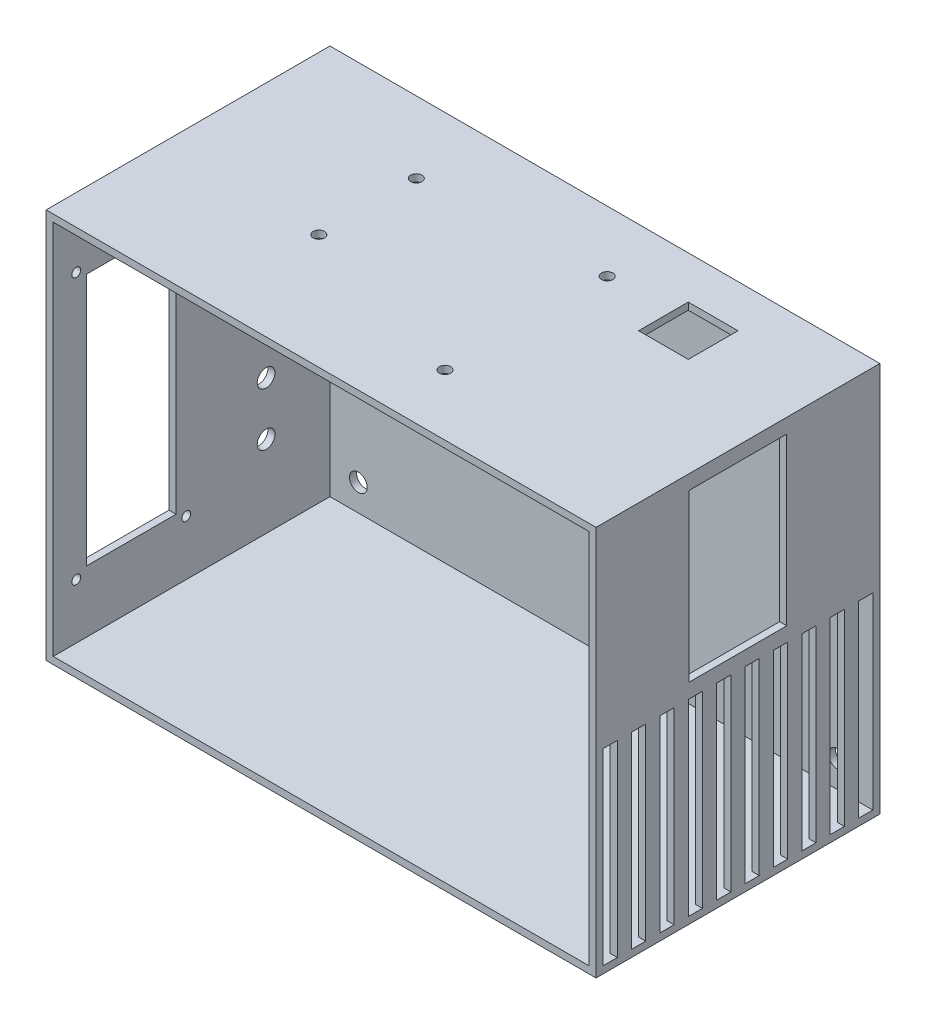
from build123d import *

# Parameters (mm, degrees)
SKETCH1_W           = 155
SKETCH1_H           = 110
BOSS_EXTRUDE1_DEPTH = 80
SKETCH2_W           = 151
SKETCH2_H           = 106
CUT_EXTRUDE1_DEPTH  = 78
SKETCH3_R           = 2.5
CUT_EXTRUDE2_DEPTH  = 2
SKETCH7_R           = 1.6
CUT_EXTRUDE7_DEPTH  = 2
SKETCH4_W           = 27.5
SKETCH4_H           = 46.8
CUT_EXTRUDE8_DEPTH  = 2
SKETCH8_W           = 4
SKETCH8_H           = 53
CUT_EXTRUDE9_DEPTH  = 2
SKETCH9_W           = 14
SKETCH9_H           = 14
CUT_EXTRUDE10_DEPTH = 2
SKETCH10_W          = 25.2
SKETCH10_H          = 71.2
SKETCH10_R          = 1.25
CUT_EXTRUDE12_DEPTH = 2
SKETCH11_R          = 2.5
SKETCH11_R_2        = 4.5
CUT_EXTRUDE13_DEPTH = 2


with BuildPart() as part:
    # Sketch1 → Boss-Extrude1 (new body)
    with BuildSketch(Plane.XY):
        with Locations((77.5, 55)):
            Rectangle(SKETCH1_W, SKETCH1_H)
    extrude(amount=BOSS_EXTRUDE1_DEPTH)

    # Sketch2 → Cut-Extrude1 (cut)
    with BuildSketch(Plane.XY.offset(80)):
        with Locations((77.5, 55)):
            Rectangle(SKETCH2_W, SKETCH2_H)
    extrude(amount=-CUT_EXTRUDE1_DEPTH, mode=Mode.SUBTRACT)

    # Sketch3 → Cut-Extrude2 (cut)
    with BuildSketch(Plane.XY.offset(2)):
        with Locations((145, 100.5)):
            Circle(SKETCH3_R)
        with Locations((145, 9.5)):
            Circle(SKETCH3_R)
        with Locations((10, 9.5)):
            Circle(SKETCH3_R)
        with Locations((10, 100.5)):
            Circle(SKETCH3_R)
    extrude(amount=-CUT_EXTRUDE2_DEPTH, mode=Mode.SUBTRACT)

    # Sketch7 → Cut-Extrude7 (cut)
    with BuildSketch(Plane(origin=(0, 110, 0), x_dir=(1, 0, 0), z_dir=(0, 1, 0))):
        with Locations((44.48, -20.14450396)):
            Circle(SKETCH7_R)
        with Locations((95.28, -17.14)):
            Circle(SKETCH7_R)
        with Locations((95.28, -62.86)):
            Circle(SKETCH7_R)
        with Locations((44.48, -47.62)):
            Circle(SKETCH7_R)
    extrude(amount=-CUT_EXTRUDE7_DEPTH, mode=Mode.SUBTRACT)

    # Sketch4 → Cut-Extrude8 (cut)
    with BuildSketch(Plane(origin=(155, 0, 0), x_dir=(0, 0, -1), z_dir=(1, 0, 0))):
        with Locations((-40, 82.5)):
            Rectangle(SKETCH4_W, SKETCH4_H)
    extrude(amount=-CUT_EXTRUDE8_DEPTH, mode=Mode.SUBTRACT)

    # Sketch8 → Cut-Extrude9 (cut)
    with BuildSketch(Plane(origin=(155, 0, 0), x_dir=(0, 0, -1), z_dir=(1, 0, 0))):
        with Locations((-68, 28.5)):
            Rectangle(SKETCH8_W, SKETCH8_H)
        with Locations((-76, 28.5)):
            Rectangle(SKETCH8_W, SKETCH8_H)
        with Locations((-60, 28.5)):
            Rectangle(SKETCH8_W, SKETCH8_H)
        with Locations((-52, 28.5)):
            Rectangle(SKETCH8_W, SKETCH8_H)
        with Locations((-44, 28.5)):
            Rectangle(SKETCH8_W, SKETCH8_H)
        with Locations((-36, 28.5)):
            Rectangle(SKETCH8_W, SKETCH8_H)
        with Locations((-28, 28.5)):
            Rectangle(SKETCH8_W, SKETCH8_H)
        with Locations((-20, 28.5)):
            Rectangle(SKETCH8_W, SKETCH8_H)
        with Locations((-12, 28.5)):
            Rectangle(SKETCH8_W, SKETCH8_H)
        with Locations((-4, 28.5)):
            Rectangle(SKETCH8_W, SKETCH8_H)
    extrude(amount=-CUT_EXTRUDE9_DEPTH, mode=Mode.SUBTRACT)

    # Sketch9 → Cut-Extrude10 (cut)
    with BuildSketch(Plane(origin=(0, 110, 0), x_dir=(1, 0, 0), z_dir=(0, 1, 0))):
        with Locations((120, -19)):
            Rectangle(SKETCH9_W, SKETCH9_H)
    extrude(amount=-CUT_EXTRUDE10_DEPTH, mode=Mode.SUBTRACT)

    # Sketch10 → Cut-Extrude12 (cut)
    with BuildSketch(Plane.ZY):
        with Locations((58, 55)):
            Rectangle(SKETCH10_W, SKETCH10_H)
        with Locations((42.5, 92.5)):
            Circle(SKETCH10_R)
        with Locations((73.5, 92.5)):
            Circle(SKETCH10_R)
        with Locations((42.5, 17.5)):
            Circle(SKETCH10_R)
        with Locations((73.5, 17.5)):
            Circle(SKETCH10_R)
    extrude(amount=-CUT_EXTRUDE12_DEPTH, mode=Mode.SUBTRACT)

    # Sketch11 → Cut-Extrude13 (cut)
    with BuildSketch(Plane.ZY):
        with Locations((20, 55)):
            Circle(SKETCH11_R)
        with Locations((20, 40)):
            Circle(SKETCH11_R)
        with Locations((20, 25)):
            Circle(SKETCH11_R)
        with Locations((20, 82.5)):
            Circle(SKETCH11_R_2)
    extrude(amount=-CUT_EXTRUDE13_DEPTH, mode=Mode.SUBTRACT)


solid = part.part
